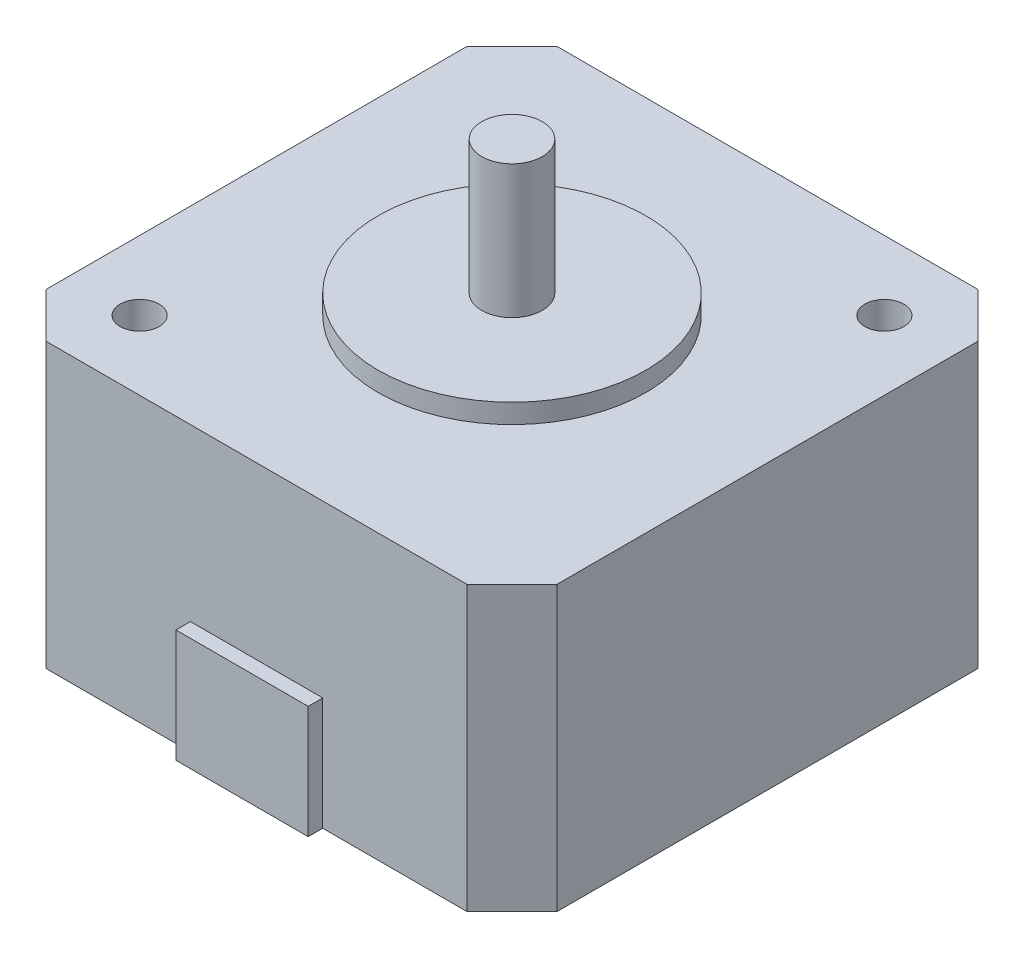
from build123d import *

# Parameters (mm, degrees)
BOSS_EXTRUDE1_DEPTH = 23.4
SKETCH2_W           = 10.92
SKETCH2_H           = 9.32
BOSS_EXTRUDE2_DEPTH = 1.2
SKETCH3_R           = 1.61
CUT_EXTRUDE1_DEPTH  = 24.4
SKETCH4_R           = 11.05
BOSS_EXTRUDE3_DEPTH = 1.6
SKETCH5_R           = 2.5
BOSS_EXTRUDE4_DEPTH = 11


with BuildPart() as part:
    # Sketch1 → Boss-Extrude1 (new body)
    with BuildSketch(Plane(origin=(0, 0, 0), x_dir=(1, 0, 0), z_dir=(0, 1, 0))):
        Polygon((-17.385, 21.085), (17.385, 21.085), (21.085, 17.385), (21.085, -17.385), (17.385, -21.085), (-17.385, -21.085), (-21.085, -17.385), (-21.085, 17.385), align=None)
    extrude(amount=BOSS_EXTRUDE1_DEPTH)

    # Sketch2 → Boss-Extrude2 (add)
    with BuildSketch(Plane.XY.offset(21.085)):
        with Locations((0, 4.66)):
            Rectangle(SKETCH2_W, SKETCH2_H)
    extrude(amount=BOSS_EXTRUDE2_DEPTH)

    # Sketch3 → Cut-Extrude1 (cut, through all)
    with BuildSketch(Plane(origin=(0, 23.4, 0), x_dir=(1, 0, 0), z_dir=(0, 1, 0))):
        with Locations((-15.37, -15.37)):
            Circle(SKETCH3_R)
        with Locations((15.37, 15.37)):
            Circle(SKETCH3_R)
    extrude(amount=-CUT_EXTRUDE1_DEPTH, mode=Mode.SUBTRACT)

    # Sketch4 → Boss-Extrude3 (add)
    with BuildSketch(Plane(origin=(0, 23.4, 0), x_dir=(1, 0, 0), z_dir=(0, 1, 0))):
        Circle(SKETCH4_R)
    extrude(amount=BOSS_EXTRUDE3_DEPTH)

    # Sketch5 → Boss-Extrude4 (add)
    with BuildSketch(Plane(origin=(0, 25, 0), x_dir=(1, 0, 0), z_dir=(0, 1, 0))):
        Circle(SKETCH5_R)
    extrude(amount=BOSS_EXTRUDE4_DEPTH)


solid = part.part
